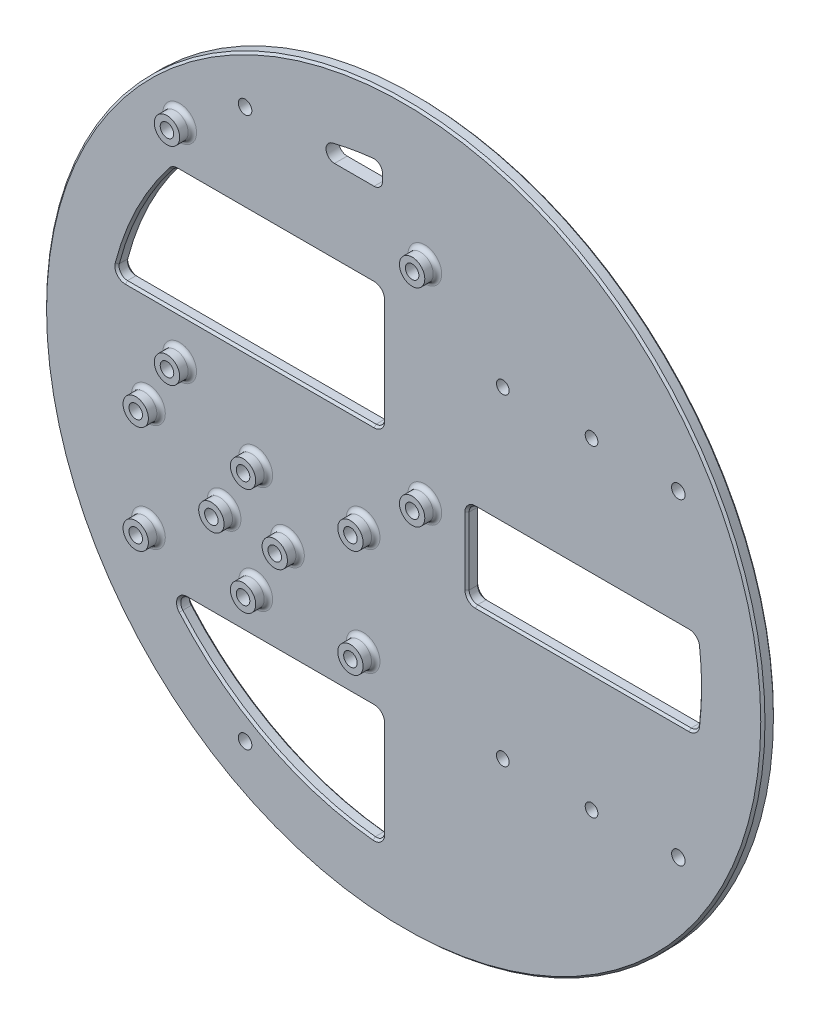
from build123d import *

# Parameters (mm, degrees)
SKETCH_1_R      = 85
SKETCH_1_R_2    = 1.6
SKETCH_1_R_3    = 1.5
EXTRUDE_1_DEPTH = 3
FILLET_1_R      = 2
SKETCH_1_3_R    = 3
SKETCH_1_3_R_2  = 1.6
EXTRUDE_2_DEPTH = 6
FILLET_2_R      = 1
CHAMFER_1_SIZE  = 0.5
CHAMFER_2_SIZE  = 0.5


with BuildPart() as part:
    # Эскиз1 → Бобышка-Вытянуть1 (new body)
    with BuildSketch(Plane.XY):
        Circle(SKETCH_1_R)
        with Locations((-37.525, -64.995206554)):
            Circle(SKETCH_1_R_2, mode=Mode.SUBTRACT)
        with BuildLine():
            Line((-55.46809894, -42.7), (-5, -42.7))
            Line((-5, -42.7), (-5, -69.821200219))
            ThreePointArc((-5, -69.821200219), (-33.135896286, -61.660460405), (-55.46809894, -42.7))
        make_face(mode=Mode.SUBTRACT)
        with Locations((23.461241313, -38.075)):
            Circle(SKETCH_1_R_3, mode=Mode.SUBTRACT)
        with Locations((44.461241313, -38.075)):
            Circle(SKETCH_1_R_3, mode=Mode.SUBTRACT)
        with Locations((64.995206554, -37.525)):
            Circle(SKETCH_1_R_2, mode=Mode.SUBTRACT)
        with BuildLine():
            Line((15, -10), (15, 10))
            Line((15, 10), (69.282032303, 10))
            ThreePointArc((69.282032303, 10), (70, 0), (69.282032303, -10))
            Line((69.282032303, -10), (15, -10))
        make_face(mode=Mode.SUBTRACT)
        with BuildLine():
            Line((-5, 44), (-5, 15))
            Line((-5, 15), (-68.373971656, 15))
            ThreePointArc((-68.373971656, 15), (-63.096984337, 30.311228408), (-54.442630355, 44))
            Line((-54.442630355, 44), (-5, 44))
        make_face(mode=Mode.SUBTRACT)
        with Locations((-37.525, 64.995206554)):
            Circle(SKETCH_1_R_2, mode=Mode.SUBTRACT)
        with BuildLine():
            ThreePointArc((-28.354893758, 64), (-16.929525315, 67.921949123), (-5, 69.821200219))
            Line((-5, 69.821200219), (-5, 64))
            Line((-5, 64), (-28.354893758, 64))
        make_face(mode=Mode.SUBTRACT)
        with Locations((23.461241313, 38.075)):
            Circle(SKETCH_1_R_3, mode=Mode.SUBTRACT)
        with Locations((44.461241313, 38.075)):
            Circle(SKETCH_1_R_3, mode=Mode.SUBTRACT)
        with Locations((64.995206554, 37.525)):
            Circle(SKETCH_1_R_2, mode=Mode.SUBTRACT)
        with Locations((-60.4, -32.7)):
            Circle(SKETCH_1_R_2, mode=Mode.SUBTRACT)
        with Locations((-60.4, -7.3)):
            Circle(SKETCH_1_R_2, mode=Mode.SUBTRACT)
        with Locations((-35, -32.7)):
            Circle(SKETCH_1_R_2, mode=Mode.SUBTRACT)
        with Locations((-9.6, -32.7)):
            Circle(SKETCH_1_R_2, mode=Mode.SUBTRACT)
        with Locations((-42.5, -20)):
            Circle(SKETCH_1_R_2, mode=Mode.SUBTRACT)
        with Locations((-27.5, -20)):
            Circle(SKETCH_1_R_2, mode=Mode.SUBTRACT)
        with Locations((-35, -7.3)):
            Circle(SKETCH_1_R_2, mode=Mode.SUBTRACT)
        with Locations((-9.6, -7.3)):
            Circle(SKETCH_1_R_2, mode=Mode.SUBTRACT)
        with Locations((-53, 5)):
            Circle(SKETCH_1_R_2, mode=Mode.SUBTRACT)
        with Locations((-53, 54)):
            Circle(SKETCH_1_R_2, mode=Mode.SUBTRACT)
        with Locations((5, 5)):
            Circle(SKETCH_1_R_2, mode=Mode.SUBTRACT)
        with Locations((5, 54)):
            Circle(SKETCH_1_R_2, mode=Mode.SUBTRACT)
    extrude(amount=EXTRUDE_1_DEPTH)

    # Скругление1
    fillet_1_edges = [part.edges().sort_by_distance(p)[0] for p in [
        (-5, -69.821200219, 1.5),
        (-5, -42.7, 1.5),
        (-55.46809894, -42.7, 1.5),
        (15, -10, 1.5),
        (15, 10, 1.5),
        (69.282032303, -10, 1.5),
        (69.282032303, 10, 1.5),
        (-5, 69.821200219, 1.5),
        (-28.354893758, 64, 1.5),
        (-5, 64, 1.5),
        (-5, 15, 1.5),
        (-68.373971656, 15, 1.5),
        (-54.442630355, 44, 1.5),
        (-5, 44, 1.5),
    ]]
    fillet(fillet_1_edges, radius=FILLET_1_R)

    # Эскиз1<3> → Бобышка-Вытянуть2 (add)
    # profile 1 of 12: a face of its own
    with BuildSketch(Plane.XY):
        with Locations((-53, 5)):
            Circle(SKETCH_1_3_R)
        with Locations((-53, 5)):
            Circle(SKETCH_1_3_R_2, mode=Mode.SUBTRACT)
    # profile 2 of 12: a face of its own
    with BuildSketch(Plane.XY):
        with Locations((5, 5)):
            Circle(SKETCH_1_3_R)
        with Locations((5, 5)):
            Circle(SKETCH_1_3_R_2, mode=Mode.SUBTRACT)
    # profile 3 of 12: a face of its own
    with BuildSketch(Plane.XY):
        with Locations((5, 54)):
            Circle(SKETCH_1_3_R)
        with Locations((5, 54)):
            Circle(SKETCH_1_3_R_2, mode=Mode.SUBTRACT)
    # profile 4 of 12: a face of its own
    with BuildSketch(Plane.XY):
        with Locations((-42.5, -20)):
            Circle(SKETCH_1_3_R)
        with Locations((-42.5, -20)):
            Circle(SKETCH_1_3_R_2, mode=Mode.SUBTRACT)
    # profile 5 of 12: a face of its own
    with BuildSketch(Plane.XY):
        with Locations((-27.5, -20)):
            Circle(SKETCH_1_3_R)
        with Locations((-27.5, -20)):
            Circle(SKETCH_1_3_R_2, mode=Mode.SUBTRACT)
    # profile 6 of 12: a face of its own
    with BuildSketch(Plane.XY):
        with Locations((-60.4, -7.3)):
            Circle(SKETCH_1_3_R)
        with Locations((-60.4, -7.3)):
            Circle(SKETCH_1_3_R_2, mode=Mode.SUBTRACT)
    # profile 7 of 12: a face of its own
    with BuildSketch(Plane.XY):
        with Locations((-35, -7.3)):
            Circle(SKETCH_1_3_R)
        with Locations((-35, -7.3)):
            Circle(SKETCH_1_3_R_2, mode=Mode.SUBTRACT)
    # profile 8 of 12: a face of its own
    with BuildSketch(Plane.XY):
        with Locations((-9.6, -7.3)):
            Circle(SKETCH_1_3_R)
        with Locations((-9.6, -7.3)):
            Circle(SKETCH_1_3_R_2, mode=Mode.SUBTRACT)
    # profile 9 of 12: a face of its own
    with BuildSketch(Plane.XY):
        with Locations((-9.6, -32.7)):
            Circle(SKETCH_1_3_R)
        with Locations((-9.6, -32.7)):
            Circle(SKETCH_1_3_R_2, mode=Mode.SUBTRACT)
    # profile 10 of 12: a face of its own
    with BuildSketch(Plane.XY):
        with Locations((-35, -32.7)):
            Circle(SKETCH_1_3_R)
        with Locations((-35, -32.7)):
            Circle(SKETCH_1_3_R_2, mode=Mode.SUBTRACT)
    # profile 11 of 12: a face of its own
    with BuildSketch(Plane.XY):
        with Locations((-60.4, -32.7)):
            Circle(SKETCH_1_3_R)
        with Locations((-60.4, -32.7)):
            Circle(SKETCH_1_3_R_2, mode=Mode.SUBTRACT)
    # profile 12 of 12: a face of its own
    with BuildSketch(Plane.XY):
        with Locations((-53, 54)):
            Circle(SKETCH_1_3_R)
        with Locations((-53, 54)):
            Circle(SKETCH_1_3_R_2, mode=Mode.SUBTRACT)
    extrude(amount=EXTRUDE_2_DEPTH)

    # Скругление2
    fillet_2_edges = [part.edges().sort_by_distance(p)[0] for p in [
        (-12.6, -32.7, 3),
        (2, 5, 3),
        (-12.6, -7.3, 3),
        (-30.5, -20, 3),
        (-38, -32.7, 3),
        (-45.5, -20, 3),
        (-63.4, -32.7, 3),
        (-56, 5, 3),
        (-63.4, -7.3, 3),
        (-38, -7.3, 3),
        (2, 54, 3),
        (-56, 54, 3),
    ]]
    fillet(fillet_2_edges, radius=FILLET_2_R)

    # Фаска1
    chamfer_1_edges = [part.edges().sort_by_distance(p)[0] for p in [
        (-85, 0, 0),
        (-85, 0, 3),
    ]]
    chamfer(chamfer_1_edges, length=CHAMFER_1_SIZE)

    # Фаска2
    chamfer_2_edges = [part.edges().sort_by_distance(p)[0] for p in [
        (42.263886032, -10, 0),
        (15.585786438, -9.414213562, 0),
        (68.856194393, -9.495090003, 0),
        (15, 0, 0),
        (70, 0, 0),
        (15.585786438, 9.414213562, 0),
        (68.856194393, 9.495090003, 0),
        (42.263886032, 10, 0),
        (-30.239483914, 44, 0),
        (-5.585786438, 43.414213562, 0),
        (-54.353442461, 43.798692335, 0),
        (-5, 29.5, 0),
        (-62.748087674, 31.027044546, 0),
        (-5.585786438, 15.585786438, 0),
        (-67.421855716, 15.775255129, 0),
        (-36.420358443, 15, 0),
        (-5.660553231, -69.123967607, 0),
        (-5, -56.169373146, 0),
        (-32.219547929, -62.144193062, 0),
        (-5.585786438, -43.285786438, 0),
        (-53.064267125, -43.872175068, 0),
        (-29.121816875, -42.7, 0),
        (-5.660553231, -69.123967607, 3),
        (-5, -56.169373146, 3),
        (-32.219547929, -62.144193062, 3),
        (-5.585786438, -43.285786438, 3),
        (-53.064267125, -43.872175068, 3),
        (-29.121816875, -42.7, 3),
        (42.263886032, -10, 3),
        (15.585786438, -9.414213562, 3),
        (68.856194393, -9.495090003, 3),
        (15, 0, 3),
        (70, 0, 3),
        (15.585786438, 9.414213562, 3),
        (68.856194393, 9.495090003, 3),
        (42.263886032, 10, 3),
        (-36.420358443, 15, 3),
        (-5.585786438, 15.585786438, 3),
        (-67.421855716, 15.775255129, 3),
        (-5, 29.5, 3),
        (-62.748087674, 31.027044546, 3),
        (-5.585786438, 43.414213562, 3),
        (-54.353442461, 43.798692335, 3),
        (-30.239483914, 44, 3),
    ]]
    chamfer(chamfer_2_edges, length=CHAMFER_2_SIZE)


solid = part.part
